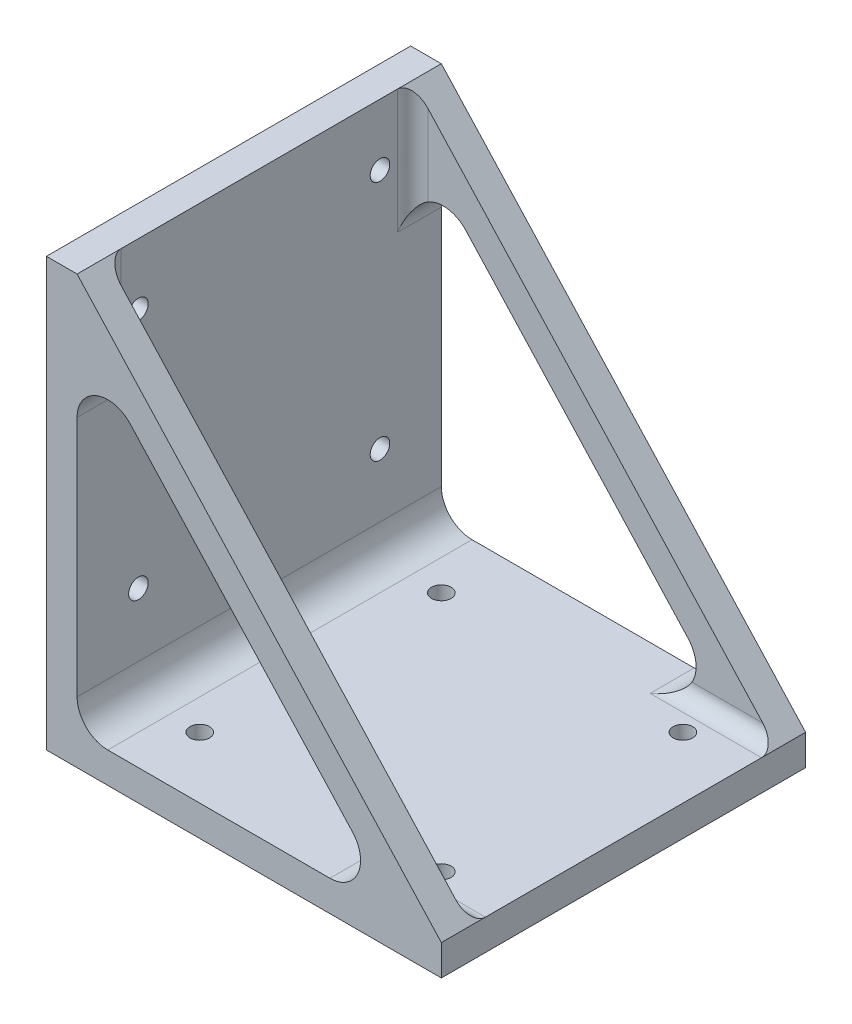
from build123d import *

# Parameters (mm, degrees)
BOSS_EXTRUDE1_START = -25.4
SKETCH1_W           = 75.4
SKETCH1_H           = 75.4
SKETCH1_R           = 2.025
BOSS_EXTRUDE1_DEPTH = 6.35
SKETCH2_W           = 75.4
SKETCH2_H           = 88.5
SKETCH2_R           = 2.025
BOSS_EXTRUDE2_DEPTH = 6.35
BOSS_EXTRUDE3_START = -37.7
BOSS_EXTRUDE3_DEPTH = 75.4
CUT_EXTRUDE1_DEPTH  = 31.75
FILLET3_R           = 6.35
FILLET4_R           = 3.175


with BuildPart() as part:
    # Sketch1 → Boss-Extrude1 (new body)
    with BuildSketch(Plane(origin=(0, 0, 0), x_dir=(1, 0, 0), z_dir=(0, 1, 0)).offset(BOSS_EXTRUDE1_START)):
        Rectangle(SKETCH1_W, SKETCH1_H)
        with Locations((-25, 25)):
            Circle(SKETCH1_R, mode=Mode.SUBTRACT)
        with Locations((25, 25)):
            Circle(SKETCH1_R, mode=Mode.SUBTRACT)
        with Locations((25, -25)):
            Circle(SKETCH1_R, mode=Mode.SUBTRACT)
        with Locations((-25, -25)):
            Circle(SKETCH1_R, mode=Mode.SUBTRACT)
    extrude(amount=-BOSS_EXTRUDE1_DEPTH)

    # Sketch2 → Boss-Extrude2 (add)
    with BuildSketch(Plane.ZY.offset(37.7)):
        with Locations((0, 12.5)):
            Rectangle(SKETCH2_W, SKETCH2_H)
        with Locations((-25, 44.05)):
            Circle(SKETCH2_R, mode=Mode.SUBTRACT)
        with Locations((-25, -5.95)):
            Circle(SKETCH2_R, mode=Mode.SUBTRACT)
        with Locations((25, -5.95)):
            Circle(SKETCH2_R, mode=Mode.SUBTRACT)
        with Locations((25, 44.05)):
            Circle(SKETCH2_R, mode=Mode.SUBTRACT)
    extrude(amount=BOSS_EXTRUDE2_DEPTH)

    # Sketch3 → Boss-Extrude3 (add)
    with BuildSketch(Plane(origin=(0, 0, 0), x_dir=(-1, 0, 0), z_dir=(0, 0, -1)).offset(BOSS_EXTRUDE3_START)):
        Polygon((-37.7, -25.4), (37.7, 56.75), (37.7, 47.359169269), (-29.08078348, -25.4), align=None)
    extrude(amount=BOSS_EXTRUDE3_DEPTH)

    # Sketch3_2 → Cut-Extrude1 (cut, symmetric)
    with BuildSketch(Plane(origin=(0, 0, 0), x_dir=(-1, 0, 0), z_dir=(0, 0, -1))):
        Polygon((-37.7, -25.4), (37.7, 56.75), (37.7, 47.359169269), (-29.08078348, -25.4), align=None)
    extrude(amount=CUT_EXTRUDE1_DEPTH, both=True, mode=Mode.SUBTRACT)

    # Fillet3
    fillet3_edges = [part.edges().sort_by_distance(p)[0] for p in [
        (-37.7, 47.359169269, -34.725),
        (-37.7, -25.4, 0),
        (29.08078348, -25.4, -34.725),
        (-37.7, 47.359169269, 34.725),
        (29.08078348, -25.4, 34.725),
    ]]
    fillet(fillet3_edges, radius=FILLET3_R)

    # Fillet4
    fillet4_edges = [part.edges().sort_by_distance(p)[0] for p in [
        (21.857054709, -25.4, 31.75),
        (-37.7, 39.204519819, 31.75),
        (21.857054709, -25.4, -31.75),
        (-37.7, 39.204519819, -31.75),
    ]]
    fillet(fillet4_edges, radius=FILLET4_R)


solid = part.part
